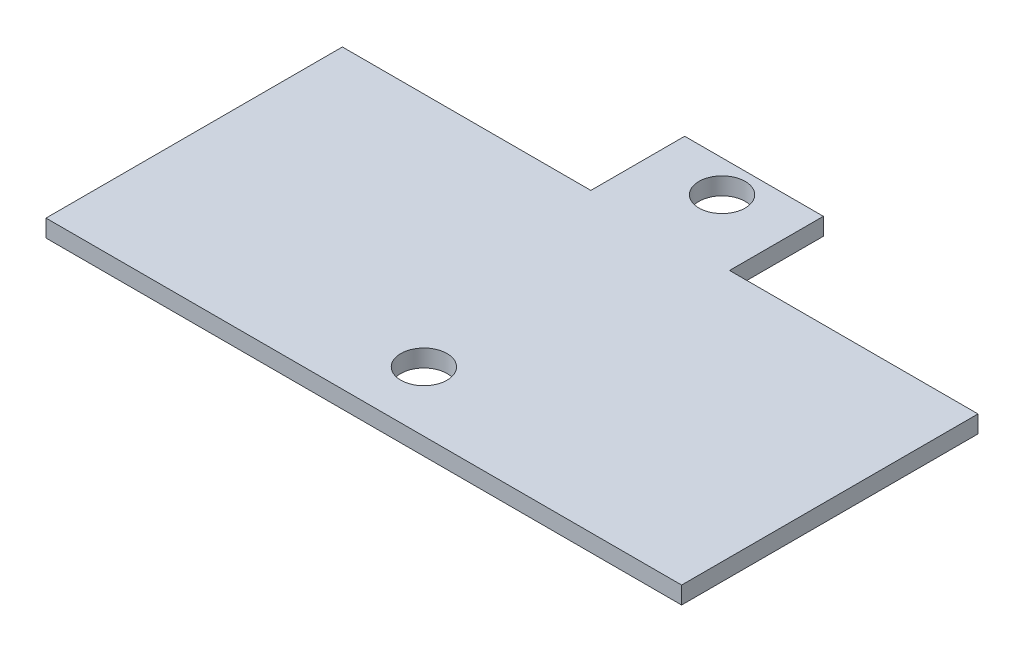
from build123d import *

# Parameters (mm, degrees)
SKETCH_1_R      = 2
EXTRUDE_1_DEPTH = 1.5


with BuildPart() as part:
    # Эскиз1 → Бобышка-Вытянуть1 (new body)
    with BuildSketch(Plane(origin=(0, 0, 0), x_dir=(1, 0, 0), z_dir=(0, 1, 0))):
        Polygon((0, 25.646468405), (21.5, 25.646468405), (21.5, 33.764912407), (33.5, 33.764912407), (33.5, 25.646468405), (55, 25.646468405), (55, 0), (0, 0), align=None)
        with Locations((27.5, 31)):
            Circle(SKETCH_1_R, mode=Mode.SUBTRACT)
        with Locations((27.5, 5.2)):
            Circle(SKETCH_1_R, mode=Mode.SUBTRACT)
    extrude(amount=EXTRUDE_1_DEPTH)


solid = part.part
